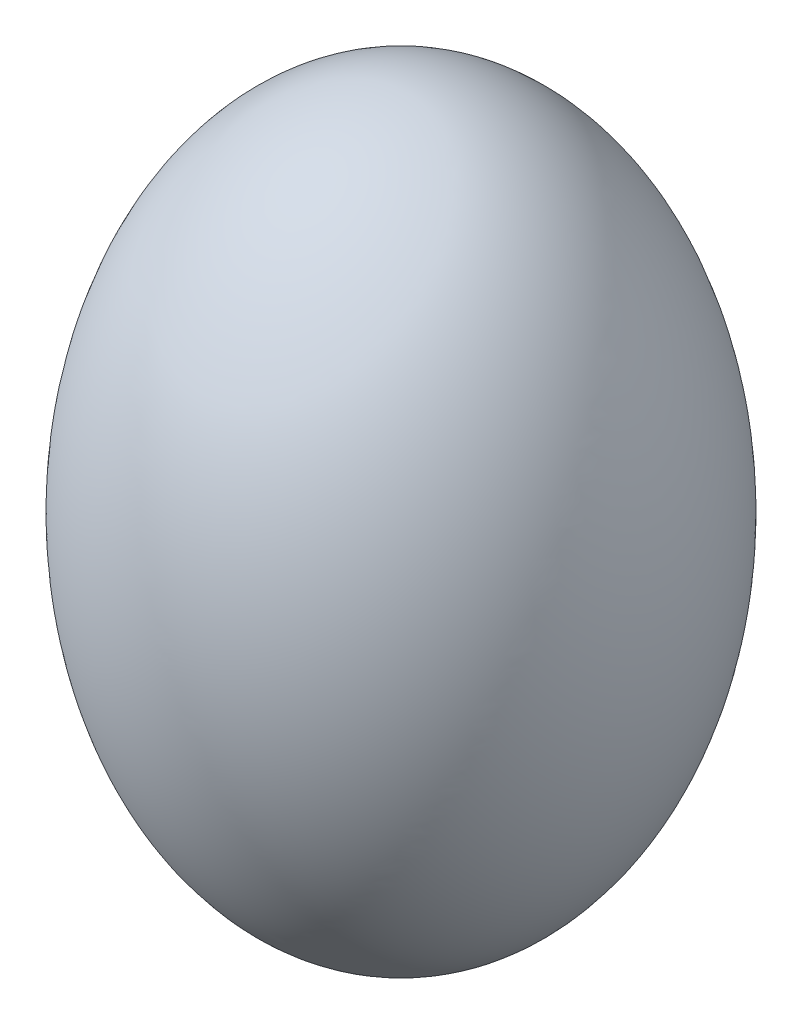
from build123d import *


with BuildPart() as part:
    # Çizim1 → Döndür1 (revolve)
    with BuildSketch(Plane.XY):
        with BuildLine():
            Line((0, -32.5), (0, 32.5))
            add(Edge.make_bspline(
                [(0, -32.5), (22.5, -32.5), (22.5, 0), (22.5, 32.5), (0, 32.5)],
                knots=[3.141592654, 3.141592654, 3.141592654, 4.71238898, 4.71238898, 6.283185307, 6.283185307, 6.283185307], degree=2, weights=[1, 0.707106781, 1, 0.707106781, 1]))
        make_face()
    revolve(axis=Axis((0, -32.5, 0), (0, 1, 0)))


solid = part.part
